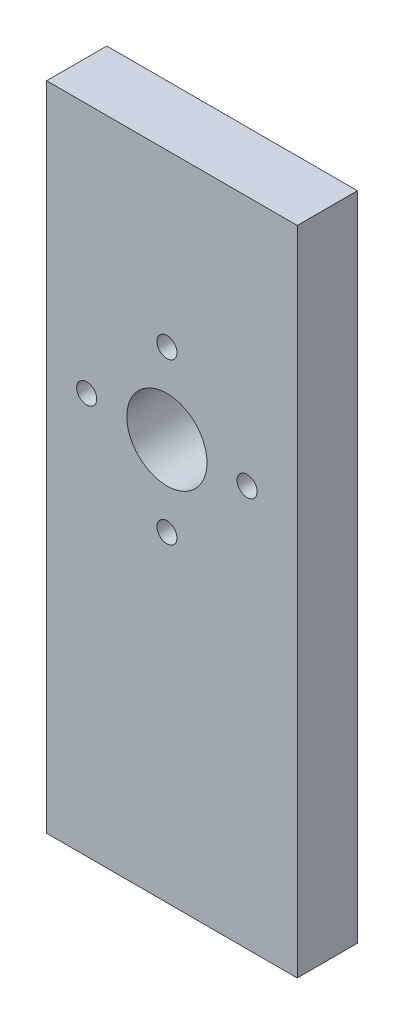
from build123d import *

# Parameters (mm, degrees)
ESQUISSE1_W             = 25
ESQUISSE1_H             = 65
ESQUISSE1_R             = 1
ESQUISSE1_R_2           = 4
BOSS_EXTRU_1_DEPTH      = 6
ESQUISSE4_R             = 1.5
ENL_V_MAT_EXTRU_3_DEPTH = 10


with BuildPart() as part:
    # Esquisse1 → Boss.-Extru.1 (new body)
    with BuildSketch(Plane.XY):
        with Locations((37.864568032, -83.170745263)):
            Rectangle(ESQUISSE1_W, ESQUISSE1_H)
        with Locations((29.364568032, -75.670745263)):
            Circle(ESQUISSE1_R, mode=Mode.SUBTRACT)
        with Locations((37.364568032, -67.670745263)):
            Circle(ESQUISSE1_R, mode=Mode.SUBTRACT)
        with Locations((45.364568032, -75.670745263)):
            Circle(ESQUISSE1_R, mode=Mode.SUBTRACT)
        with Locations((37.364568032, -83.670745263)):
            Circle(ESQUISSE1_R, mode=Mode.SUBTRACT)
        with Locations((37.364568032, -75.670745263)):
            Circle(ESQUISSE1_R_2, mode=Mode.SUBTRACT)
    extrude(amount=BOSS_EXTRU_1_DEPTH)

    # Esquisse4 → Enlèv. mat.-Extru.3 (cut)
    with BuildSketch(Plane.ZY.offset(-25.364568032)):
        with Locations((3, -55.670745263)):
            Circle(ESQUISSE4_R)
        with Locations((3, -110.670745263)):
            Circle(ESQUISSE4_R)
    extrude(amount=-ENL_V_MAT_EXTRU_3_DEPTH, mode=Mode.SUBTRACT)


solid = part.part
